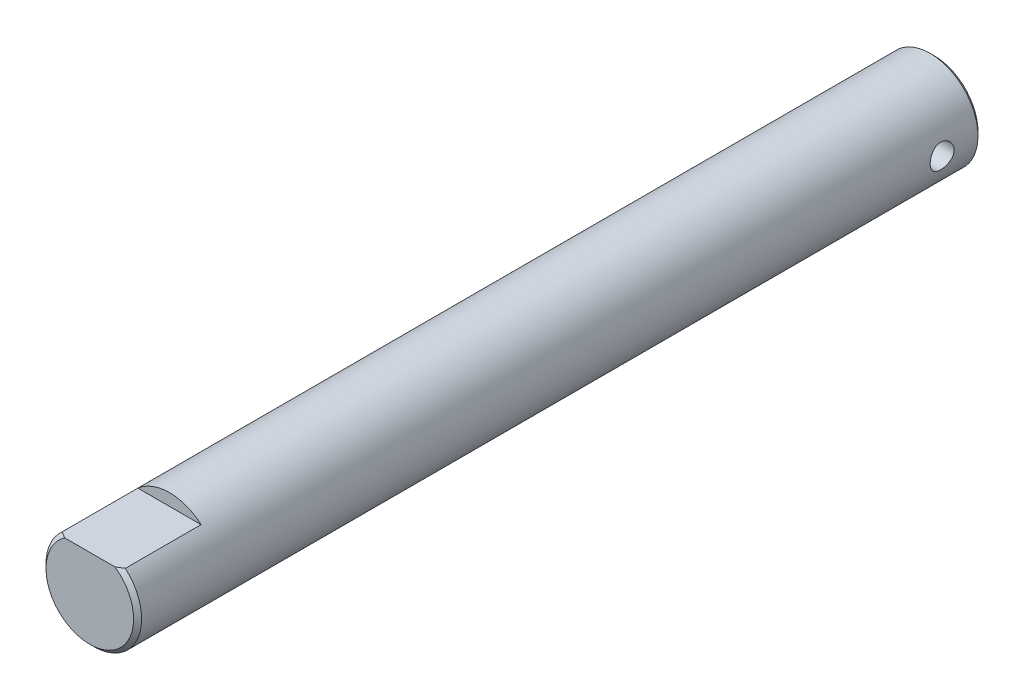
from build123d import *

# Parameters (mm, degrees)
SKETCH1_R              = 6
SHAFT_DEPTH            = 53
HOLE_REACH             = 8
SKETCH2_R              = 1.5
HOLE_DIRECTION_2_REACH = 8
F_0_5X45_CHAMFERS_SIZE = 0.5
FLAT_DEPTH             = 10


with BuildPart() as part:
    # Sketch1 → Shaft (new body, symmetric)
    with BuildSketch(Plane.XY):
        Circle(SKETCH1_R)
    extrude(amount=SHAFT_DEPTH, both=True)

    # Sketch2 → Hole (cut, up to next)
    with BuildSketch(Plane(origin=(0, 0, 0), x_dir=(0, 0, -1), z_dir=(1, 0, 0)), mode=Mode.PRIVATE) as hole_sk1:
        with Locations((48, 0)):
            Circle(SKETCH2_R)
    hole_tool1 = extrude(hole_sk1.sketch, amount=-HOLE_REACH, mode=Mode.PRIVATE) & part.part
    add(hole_tool1.solids().sort_by_distance((0, 0, -48))[0], mode=Mode.SUBTRACT)

    # Sketch2 → Hole direction 2 (cut, up to next)
    with BuildSketch(Plane(origin=(0, 0, 0), x_dir=(0, 0, -1), z_dir=(1, 0, 0)), mode=Mode.PRIVATE) as hole_direction_2_sk1:
        with Locations((48, 0)):
            Circle(SKETCH2_R)
    hole_direction_2_tool1 = extrude(hole_direction_2_sk1.sketch, amount=HOLE_DIRECTION_2_REACH, mode=Mode.PRIVATE) & part.part
    add(hole_direction_2_tool1.solids().sort_by_distance((0, 0, -48))[0], mode=Mode.SUBTRACT)

    # 0.5x45 Chamfers
    f_0_5x45_chamfers_edges = [part.edges().sort_by_distance(p)[0] for p in [
        (-6, 0, -53),
        (-6, 0, 53),
    ]]
    chamfer(f_0_5x45_chamfers_edges, length=F_0_5X45_CHAMFERS_SIZE)

    # Sketch4 → Flat (cut)
    with BuildSketch(Plane.XY.offset(53)):
        with BuildLine():
            Line((-3.968626967, 4.5), (3.968626967, 4.5))
            ThreePointArc((3.968626967, 4.5), (0, 6), (-3.968626967, 4.5))
        make_face()
    extrude(amount=-FLAT_DEPTH, mode=Mode.SUBTRACT)


solid = part.part
